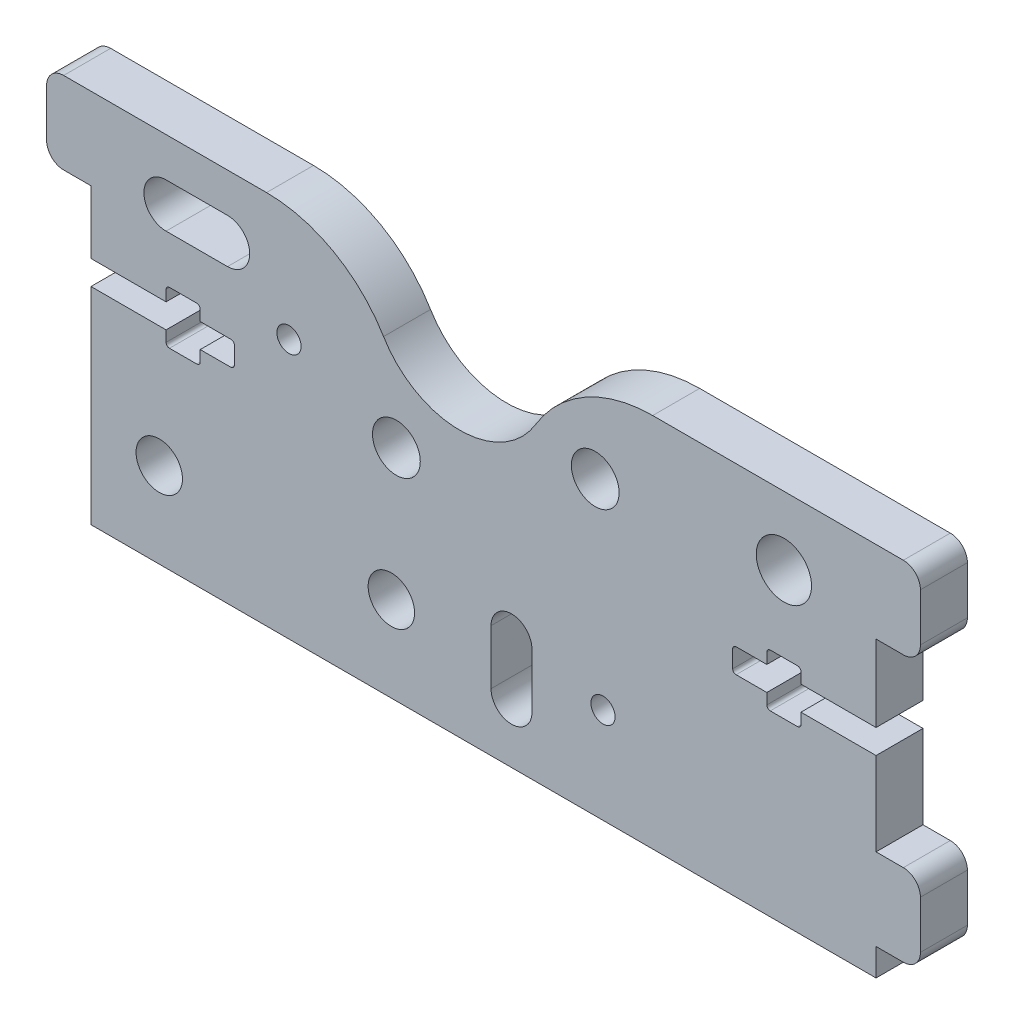
from build123d import *

# Parameters (mm, degrees)
SKETCH1_W           = 115
SKETCH1_H           = 55
BOSS_EXTRUDE1_DEPTH = 6.88
SKETCH2_R           = 3.4
CUT_EXTRUDE1_DEPTH  = 7.88
SKETCH4_R           = 1.775
CUT_EXTRUDE3_DEPTH  = 7.88
SKETCH6_W           = 13
SKETCH6_H           = 12
SKETCH6_W_2         = 19
BOSS_EXTRUDE2_DEPTH = 6.88
SKETCH7_W           = 42
SKETCH7_H           = 3.55
CUT_EXTRUDE4_DEPTH  = 7.88
SKETCH8_W           = 5
SKETCH8_H           = 7.72
CUT_EXTRUDE5_DEPTH  = 7.88
SKETCH10_W          = 42
SKETCH10_H          = 3.55
CUT_EXTRUDE7_DEPTH  = 7.88
SKETCH11_W          = 5
SKETCH11_H          = 7.72
CUT_EXTRUDE8_DEPTH  = 7.88
FILLET1_R           = 0.5
CUT_EXTRUDE10_DEPTH = 7.88
SKETCH14_W          = 6.5
SKETCH14_H          = 12
BOSS_EXTRUDE3_DEPTH = 6.88
SKETCH15_R          = 13
CUT_EXTRUDE11_DEPTH = 7.88
FILLET2_R           = 20
SKETCH17_R          = 4.05
CUT_EXTRUDE12_DEPTH = 7.88
FILLET3_R           = 2.5
SKETCH18_R          = 3.5
CUT_EXTRUDE13_DEPTH = 7.88


with BuildPart() as part:
    # Sketch1 → Boss-Extrude1 (new body)
    with BuildSketch(Plane.XY):
        Rectangle(SKETCH1_W, SKETCH1_H)
    extrude(amount=BOSS_EXTRUDE1_DEPTH)

    # Sketch2 → Cut-Extrude1 (cut, through all)
    with BuildSketch(Plane.XY.offset(6.88)):
        with Locations((-47.5, -15)):
            Circle(SKETCH2_R)
        with Locations((-13.5, -15)):
            Circle(SKETCH2_R)
    extrude(amount=-CUT_EXTRUDE1_DEPTH, mode=Mode.SUBTRACT)

    # Sketch4 → Cut-Extrude3 (cut, through all)
    with BuildSketch(Plane.XY.offset(6.88)):
        with Locations((17.5, -13.5)):
            Circle(SKETCH4_R)
        with Locations((-28.5, 10.5)):
            Circle(SKETCH4_R)
    extrude(amount=-CUT_EXTRUDE3_DEPTH, mode=Mode.SUBTRACT)

    # Sketch6 → Boss-Extrude2 (add)
    with BuildSketch(Plane.XY.offset(6.88)):
        with Locations((57.5, 21.5)):
            Rectangle(SKETCH6_W, SKETCH6_H)
        with Locations((54.5, -17.5)):
            Rectangle(SKETCH6_W_2, SKETCH6_H)
    extrude(amount=-BOSS_EXTRUDE2_DEPTH)

    # Sketch7 → Cut-Extrude4 (cut, through all)
    with BuildSketch(Plane.XY.offset(6.88)):
        with Locations((57.5, 2.5)):
            Rectangle(SKETCH7_W, SKETCH7_H)
    extrude(amount=-CUT_EXTRUDE4_DEPTH, mode=Mode.SUBTRACT)

    # Sketch8 → Cut-Extrude5 (cut, through all)
    with BuildSketch(Plane.XY.offset(6.88)):
        with Locations((44, 2.5)):
            Rectangle(SKETCH8_W, SKETCH8_H)
    extrude(amount=-CUT_EXTRUDE5_DEPTH, mode=Mode.SUBTRACT)

    # Sketch10 → Cut-Extrude7 (cut, through all)
    with BuildSketch(Plane.XY.offset(6.88)):
        with Locations((-57.5, 4.5)):
            Rectangle(SKETCH10_W, SKETCH10_H)
    extrude(amount=-CUT_EXTRUDE7_DEPTH, mode=Mode.SUBTRACT)

    # Sketch11 → Cut-Extrude8 (cut, through all)
    with BuildSketch(Plane.XY.offset(6.88)):
        with Locations((-44, 4.5)):
            Rectangle(SKETCH11_W, SKETCH11_H)
    extrude(amount=-CUT_EXTRUDE8_DEPTH, mode=Mode.SUBTRACT)

    # Fillet1
    fillet1_edges = [part.edges().sort_by_distance(p)[0] for p in [
        (46.5, 6.36, 3.44),
        (41.5, -1.36, 3.44),
        (46.5, -1.36, 3.44),
        (41.5, 6.36, 3.44),
        (-36.5, 2.725, 3.44),
        (-36.5, 6.275, 3.44),
        (-41.5, 8.36, 3.44),
        (-46.5, 0.64, 3.44),
        (-41.5, 0.64, 3.44),
        (-46.5, 8.36, 3.44),
        (36.5, 4.275, 3.44),
        (36.5, 0.725, 3.44),
    ]]
    fillet(fillet1_edges, radius=FILLET1_R)

    # Sketch13 → Cut-Extrude10 (cut, through all)
    with BuildSketch(Plane.XY.offset(6.88)):
        with BuildLine():
            Line((7.1, -11), (7.1, -19))
            ThreePointArc((7.1, -19), (4.1, -22), (1.1, -19))
            Line((1.1, -19), (1.1, -11))
            ThreePointArc((1.1, -11), (4.1, -8), (7.1, -11))
        make_face()
    extrude(amount=-CUT_EXTRUDE10_DEPTH, mode=Mode.SUBTRACT)

    # Sketch14 → Boss-Extrude3 (add)
    with BuildSketch(Plane.XY.offset(6.88)):
        with Locations((-60.75, 21.5)):
            Rectangle(SKETCH14_W, SKETCH14_H)
    extrude(amount=-BOSS_EXTRUDE3_DEPTH)

    # Sketch15 → Cut-Extrude11 (cut, through all)
    with BuildSketch(Plane.XY.offset(6.88)):
        with Locations((-3.5, 24.5)):
            Circle(SKETCH15_R)
    extrude(amount=-CUT_EXTRUDE11_DEPTH, mode=Mode.SUBTRACT)

    # Fillet2
    fillet2_edges = [part.edges().sort_by_distance(p)[0] for p in [
        (9.149110641, 27.5, 3.44),
        (-16.149110641, 27.5, 3.44),
    ]]
    fillet(fillet2_edges, radius=FILLET2_R)

    # Sketch17 → Cut-Extrude12 (cut, through all)
    with BuildSketch(Plane.XY.offset(6.88)):
        with Locations((44, 17.5)):
            Circle(SKETCH17_R)
        with BuildLine():
            Line((-46.5, 21.75), (-37.5, 21.75))
            ThreePointArc((-37.5, 21.75), (-34.25, 18.5), (-37.5, 15.25))
            Line((-37.5, 15.25), (-46.5, 15.25))
            ThreePointArc((-46.5, 15.25), (-49.75, 18.5), (-46.5, 21.75))
        make_face()
    extrude(amount=-CUT_EXTRUDE12_DEPTH, mode=Mode.SUBTRACT)

    # Fillet3
    fillet3_edges = [part.edges().sort_by_distance(p)[0] for p in [
        (-64, 27.5, 3.44),
        (-64, 15.5, 3.44),
        (64, 15.5, 3.44),
        (64, 27.5, 3.44),
        (64, -23.5, 3.44),
        (64, -11.5, 3.44),
    ]]
    fillet(fillet3_edges, radius=FILLET3_R)

    # Sketch18 → Cut-Extrude13 (cut, through all)
    with BuildSketch(Plane.XY.offset(6.88)):
        with Locations((-12.763923401, 4.633452156)):
            Circle(SKETCH18_R)
        with Locations((16.366547844, 15.236076599)):
            Circle(SKETCH18_R)
    extrude(amount=-CUT_EXTRUDE13_DEPTH, mode=Mode.SUBTRACT)


solid = part.part
